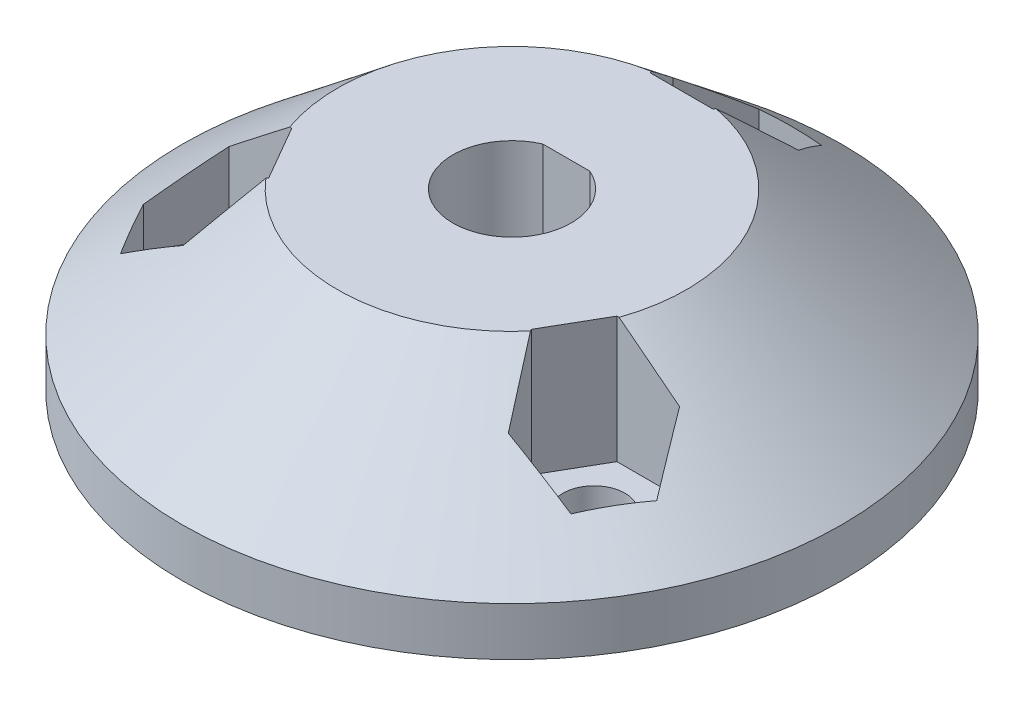
from build123d import *

# Parameters (mm, degrees)
ENL_V_START                  = 2.5
ESQUISSE5_R                  = 1.6
ENL_V_MAT_EXTRU_1_DEPTH      = 24.170995306
ESQUISSE5_2_R                = 1.6
ENL_V_MAT_EXTRU_2_DEPTH      = 26.670995306
R_P_TITION_CIRCULAIRE1_COUNT = 3
ENL_V_MAT_EXTRU_3_DEPTH      = 29.337254631


with BuildPart() as part:
    # Esquisse3 → R_volution1 (revolve)
    with BuildSketch(Plane.XY):
        Polygon((0, 9), (0, -6), (6.4, -6), (6.4, 0), (17, 0), (17, 2.5), (9, 9), align=None)
    revolve(axis=Axis((0, 0, 0), (0, 1, 0)))

    # Esquisse5 → Enl_v. mat.-Extru.1 (cut, through all)
    with BuildSketch(Plane(origin=(0, 0, 0), x_dir=(1, 0, 0), z_dir=(0, 1, 0)).offset(ENL_V_START)):
        Polygon((1.616580754, 8.747005384), (3.233161507, 11.547005384), (1.616580754, 14.347005384), (-1.616580754, 14.347005384), (-3.233161507, 11.547005384), (-1.616580754, 8.747005384), align=None)
        with Locations((0, 11.547005384)):
            Circle(ESQUISSE5_R, mode=Mode.SUBTRACT)
    enl_v_mat_extru_1 = extrude(amount=ENL_V_MAT_EXTRU_1_DEPTH, mode=Mode.SUBTRACT)

    # Esquisse5_2 → Enl_v. mat.-Extru.2 (cut, symmetric)
    with BuildSketch(Plane(origin=(0, 0, 0), x_dir=(1, 0, 0), z_dir=(0, 1, 0))):
        with Locations((0, 11.547005384)):
            Circle(ESQUISSE5_2_R)
    enl_v_mat_extru_2 = extrude(amount=ENL_V_MAT_EXTRU_2_DEPTH, both=True, mode=Mode.SUBTRACT)

    # R_p_tition circulaire1: Enl_v. mat.-Extru.1, Enl_v. mat.-Extru.2 ×3 about axis
    r_p_tition_circulaire1_axis = Axis((0, 9.75, 0), (0, -1, 0))
    add([enl_v_mat_extru_1.rotate(r_p_tition_circulaire1_axis, i * 360 / R_P_TITION_CIRCULAIRE1_COUNT) for i in range(1, R_P_TITION_CIRCULAIRE1_COUNT)], mode=Mode.SUBTRACT)
    add([enl_v_mat_extru_2.rotate(r_p_tition_circulaire1_axis, i * 360 / R_P_TITION_CIRCULAIRE1_COUNT) for i in range(1, R_P_TITION_CIRCULAIRE1_COUNT)], mode=Mode.SUBTRACT)

    # Esquisse6 → Enl_v. mat.-Extru.3 (cut, through all)
    with BuildSketch(Plane(origin=(0, 9, 0), x_dir=(1, 0, 0), z_dir=(0, 1, 0))):
        with BuildLine():
            Line((1.209338662, 2.8), (-1.209338662, 2.8))
            ThreePointArc((-1.209338662, 2.8), (-1.675412946, -2.548625406), (3.05, 0))
            ThreePointArc((3.05, 0), (2.548625406, 1.675412946), (1.209338662, 2.8))
        make_face()
    extrude(amount=-ENL_V_MAT_EXTRU_3_DEPTH, mode=Mode.SUBTRACT)


solid = part.part
